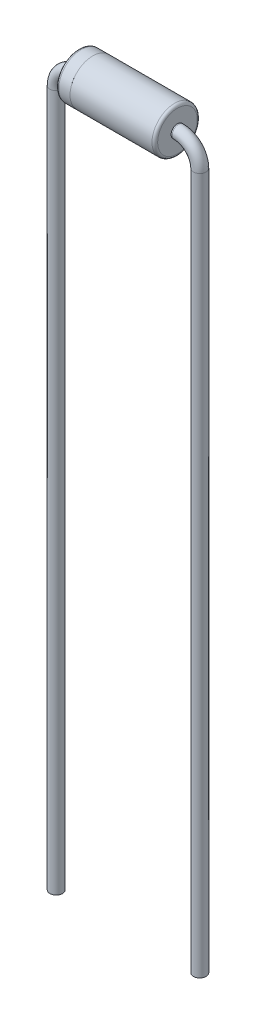
from build123d import *

# Parameters (mm, degrees)
SKETCH2_R = 0.225


with BuildPart() as part:
    # Sweep1: sweep along a path in Sketch1
    with BuildLine(Plane.XY) as sweep1_path:
        Line((-2.54, -25.4), (-2.54, -0.75))
        ThreePointArc((-2.54, -0.75), (-2.320330086, -0.219669914), (-1.79, 0))
        Line((-1.79, 0), (1.79, 0))
        ThreePointArc((1.79, 0), (2.320330086, -0.219669914), (2.54, -0.75))
        Line((2.54, -0.75), (2.54, -25.4))
    # Sketch2 → Sweep1 (sweep)
    with BuildSketch(Plane(origin=(-2.54, -25.4, 0), x_dir=(-1, 0, 0), z_dir=(0, -1, 0))):
        Circle(SKETCH2_R)
    sweep(path=sweep1_path.line)


with BuildPart() as body_2:
    # Sketch3 → Revolve1 (revolve)
    with BuildSketch(Plane.XY, mode=Mode.PRIVATE) as revolve1_sk:
        with BuildLine():
            Line((-1.4, 0.5), (-0.1, 0.5))
            ThreePointArc((-0.1, 0.5), (-0.064644661, 0.485355339), (-0.05, 0.45))
            Line((-0.05, 0.45), (-0.05, 0.3))
            Line((-0.05, 0.3), (0.05, 0.3))
            Line((0.05, 0.3), (0.05, 0.45))
            ThreePointArc((0.05, 0.45), (0.064644661, 0.485355339), (0.1, 0.5))
            Line((0.1, 0.5), (1.4, 0.5))
            ThreePointArc((1.4, 0.5), (1.470710678, 0.470710678), (1.5, 0.4))
            Line((1.5, 0.4), (1.5, 0))
            Line((1.5, 0), (-1.5, 0))
            Line((-1.5, 0), (-1.5, 0.4))
            ThreePointArc((-1.5, 0.4), (-1.470710678, 0.470710678), (-1.4, 0.5))
        make_face()
    revolve(revolve1_sk.sketch.rotate(Axis((-1.5, 0, 0), (1, 0, 0)), 90), axis=Axis((-1.5, 0, 0), (1, 0, 0)))


with BuildPart() as body_3:
    # Sketch4 → Revolve3 (revolve)
    with BuildSketch(Plane.XY, mode=Mode.PRIVATE) as revolve3_sk:
        with BuildLine():
            Line((-1.25, 0), (-1.25, 0.8))
            Line((-1.25, 0.8), (1.65, 0.8))
            ThreePointArc((1.65, 0.8), (1.720710678, 0.770710678), (1.75, 0.7))
            Line((1.75, 0.7), (1.75, 0))
            Line((1.75, 0), (-1.25, 0))
        make_face()
    revolve(revolve3_sk.sketch.rotate(Axis((-1.25, 0, 0), (1, 0, 0)), 90), axis=Axis((-1.25, 0, 0), (1, 0, 0)))


with BuildPart() as body_4:
    # Sketch5 → Revolve4 (revolve)
    with BuildSketch(Plane.XY):
        with BuildLine():
            Line((-1.25, 0), (-1.75, 0))
            Line((-1.75, 0), (-1.75, 0.7))
            ThreePointArc((-1.75, 0.7), (-1.720710678, 0.770710678), (-1.65, 0.8))
            Line((-1.65, 0.8), (-1.25, 0.8))
            Line((-1.25, 0.8), (-1.25, 0))
        make_face()
        with BuildLine():
            Line((-1.33, 0.72), (-1.65, 0.72))
            ThreePointArc((-1.65, 0.72), (-1.664142136, 0.714142136), (-1.67, 0.7))
            Line((-1.67, 0.7), (-1.67, 0.08))
            Line((-1.67, 0.08), (-1.33, 0.08))
            Line((-1.33, 0.08), (-1.33, 0.72))
        make_face(mode=Mode.SUBTRACT)
    revolve(axis=Axis((-1.25, 0, 0), (-1, 0, 0)))


solid = Compound([part.part, body_2.part, body_3.part, body_4.part])
